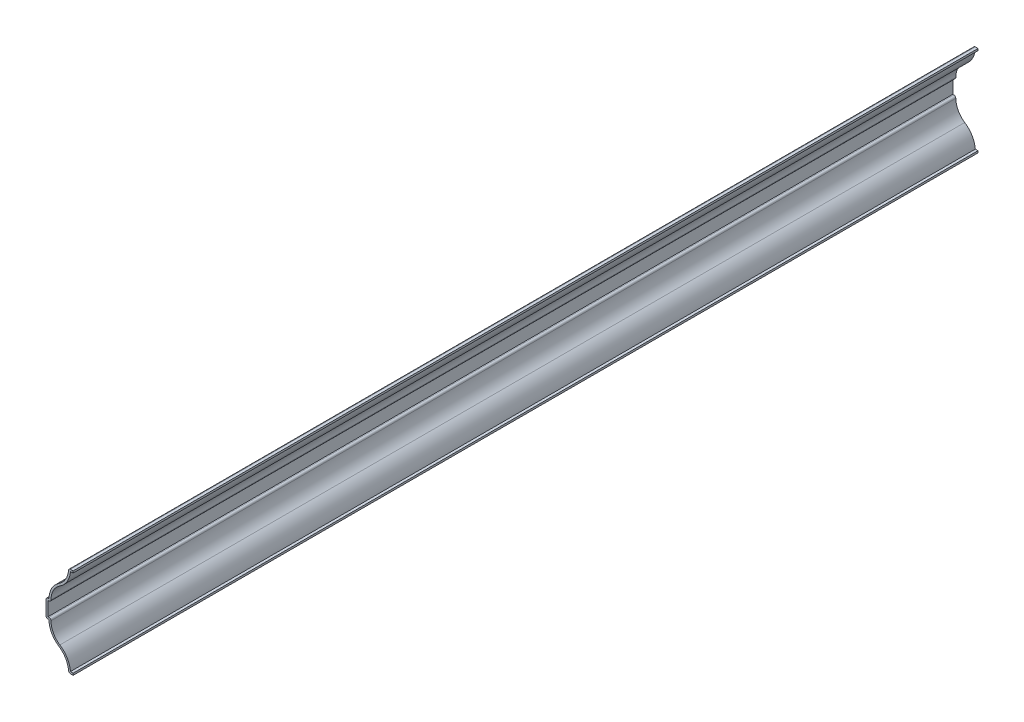
from build123d import *

# Parameters (mm, degrees)
EXTRUDE_THIN1_DEPTH = 476.25
FILLET1_R           = 1.016


with BuildPart() as part:
    # Sketch1 → Extrude-Thin1 (new body)
    with BuildSketch(Plane.XY):
        with BuildLine():
            Line((0, 0), (-2.38125, 0))
            ThreePointArc((-2.38125, 0), (-3.753941176, 5.416289675), (-7.540625, 9.525))
            ThreePointArc((-7.540625, 9.525), (-11.327308824, 13.633710325), (-12.7, 19.05))
            Line((-12.7, 19.05), (-14.2875, 19.05))
            Line((-14.2875, 19.05), (-14.2875, 28.575))
            Line((-14.2875, 28.575), (-12.7, 28.575))
            ThreePointArc((-12.7, 28.575), (-11.327308824, 33.991289675), (-7.540625, 38.1))
            ThreePointArc((-7.540625, 38.1), (-3.753941176, 42.208710325), (-2.38125, 47.625))
            Line((-2.38125, 47.625), (0, 47.625))
            Line((0, 47.625), (0, 46.609))
            Line((0, 46.609), (-1.40698386, 46.609))
            ThreePointArc((-1.40698386, 46.609), (-3.111914342, 41.282721024), (-6.985575336, 37.249014765))
            ThreePointArc((-6.985575336, 37.249014765), (-10.665203574, 33.054213727), (-11.634040924, 27.559))
            Line((-11.634040924, 27.559), (-13.2715, 27.559))
            Line((-13.2715, 27.559), (-13.2715, 20.066))
            Line((-13.2715, 20.066), (-11.634040924, 20.066))
            ThreePointArc((-11.634040924, 20.066), (-10.665203574, 14.570786273), (-6.985575336, 10.375985235))
            ThreePointArc((-6.985575336, 10.375985235), (-3.111914342, 6.342278976), (-1.40698386, 1.016))
            Line((-1.40698386, 1.016), (0, 1.016))
            Line((0, 1.016), (0, 0))
        make_face()
    extrude(amount=-EXTRUDE_THIN1_DEPTH)

    # Fillet1
    fillet1_edges = [part.edges().sort_by_distance(p)[0] for p in [
        (-2.38125, 0, -238.125),
        (-14.2875, 19.05, -238.125),
        (-14.2875, 28.575, -238.125),
        (-2.38125, 47.625, -238.125),
        (-11.634040924, 27.559, -238.125),
        (-11.634040924, 20.066, -238.125),
    ]]
    fillet(fillet1_edges, radius=FILLET1_R)


solid = part.part
